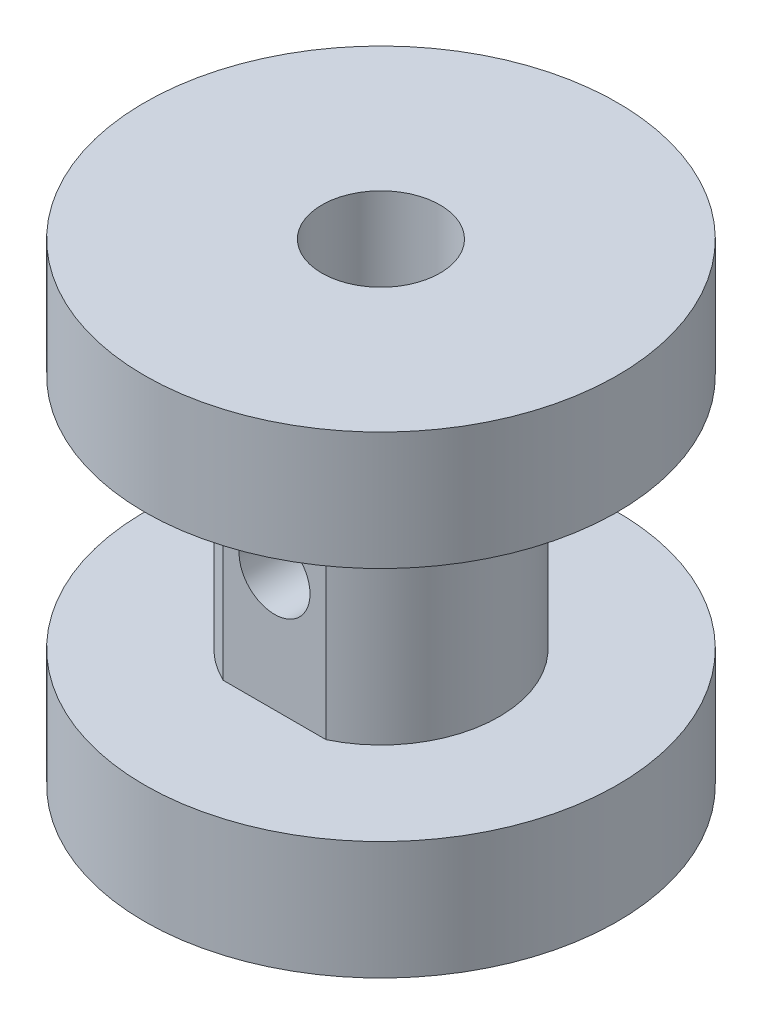
from build123d import *

# Parameters (mm, degrees)
SKETCH1_R           = 10
SKETCH1_R_2         = 2.5
BOSS_EXTRUDE1_DEPTH = 10
SKETCH1_3_R         = 10
CUT_EXTRUDE1_DEPTH  = 5
CUT_EXTRUDE2_REACH  = 22.255
SKETCH4_R           = 1.5


with BuildPart() as part:
    # Sketch1 → Boss-Extrude1 (new, symmetric)
    with BuildSketch(Plane(origin=(0, 0, 0), x_dir=(1, 0, 0), z_dir=(0, 1, 0))):
        Circle(SKETCH1_R)
        Circle(SKETCH1_R_2, mode=Mode.SUBTRACT)
    extrude(amount=BOSS_EXTRUDE1_DEPTH, both=True)

    # Sketch1_3 → Cut-Extrude1 (cut, symmetric)
    with BuildSketch(Plane(origin=(0, 0, 0), x_dir=(1, 0, 0), z_dir=(0, 1, 0))):
        Circle(SKETCH1_3_R)
        with BuildLine():
            Line((2.179449472, -4.5), (-2.179449472, -4.5))
            ThreePointArc((-2.179449472, -4.5), (0, 5), (2.179449472, -4.5))
        make_face(mode=Mode.SUBTRACT)
    extrude(amount=CUT_EXTRUDE1_DEPTH, both=True, mode=Mode.SUBTRACT)

    # Sketch4 → Cut-Extrude2 (cut, up to next)
    with BuildSketch(Plane.XY.offset(4.5), mode=Mode.PRIVATE) as cut_extrude2_sk1:
        Circle(SKETCH4_R)
    cut_extrude2_tool1 = extrude(cut_extrude2_sk1.sketch, amount=-CUT_EXTRUDE2_REACH, mode=Mode.PRIVATE) & part.part
    add(cut_extrude2_tool1.solids().sort_by_distance((0, 0, 4.5))[0], mode=Mode.SUBTRACT)


solid = part.part
